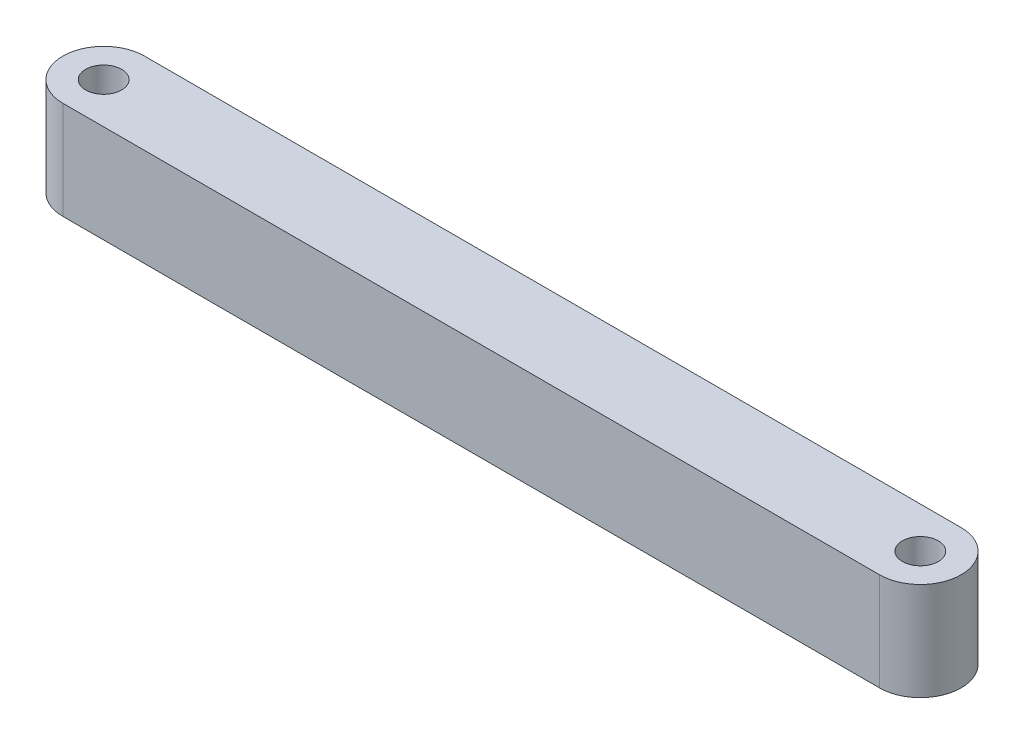
from build123d import *

# Parameters (mm, degrees)
SKETCH1_R           = 2.2
BOSS_EXTRUDE1_DEPTH = 12


with BuildPart() as part:
    # Sketch1 → Boss-Extrude1 (new body)
    with BuildSketch(Plane(origin=(0, 0, 0), x_dir=(1, 0, 0), z_dir=(0, 1, 0))):
        with BuildLine():
            ThreePointArc((-6.535515489, 3.580947173), (-11.535515489, -1.419052827), (-6.535515489, -6.419052827))
            Line((-6.535515489, -6.419052827), (93.464484511, -6.419052827))
            ThreePointArc((93.464484511, -6.419052827), (98.464484511, -1.419052827), (93.464484511, 3.580947173))
            Line((93.464484511, 3.580947173), (-6.535515489, 3.580947173))
        make_face()
        with Locations((-6.535515489, -1.419052827)):
            Circle(SKETCH1_R, mode=Mode.SUBTRACT)
        with Locations((93.464484511, -1.419052827)):
            Circle(SKETCH1_R, mode=Mode.SUBTRACT)
    extrude(amount=BOSS_EXTRUDE1_DEPTH)


solid = part.part
